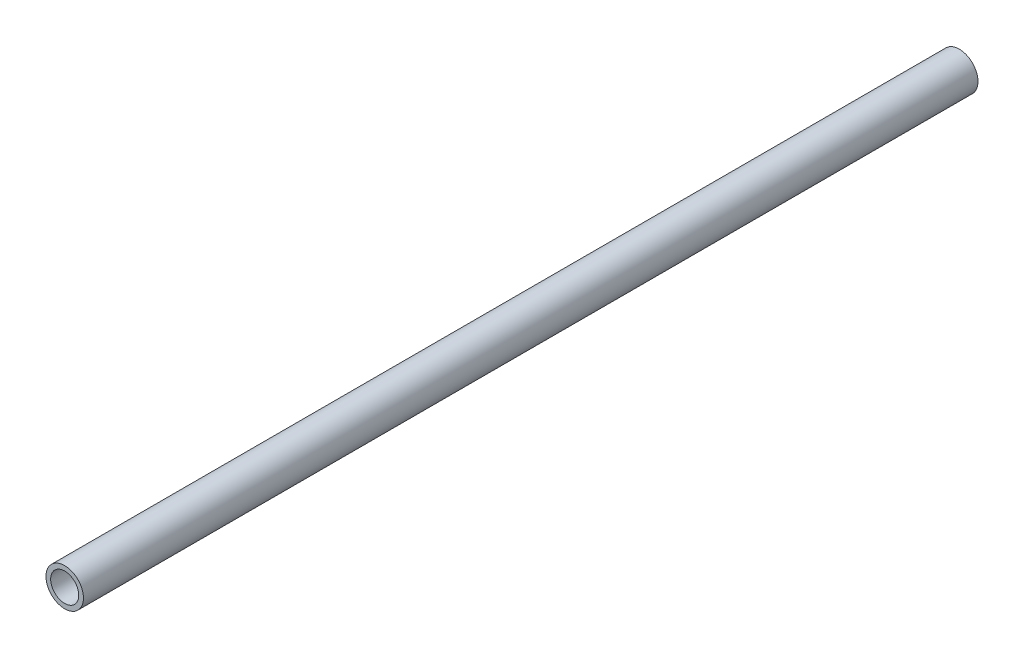
from build123d import *

# Parameters (mm, degrees)
SKETCH_1_R      = 8
SKETCH_1_R_2    = 6
EXTRUDE_1_DEPTH = 382


with BuildPart() as part:
    # 草图1 → 凸台-拉伸1 (new body)
    with BuildSketch(Plane.XY):
        Circle(SKETCH_1_R)
        Circle(SKETCH_1_R_2, mode=Mode.SUBTRACT)
    extrude(amount=EXTRUDE_1_DEPTH)


solid = part.part
